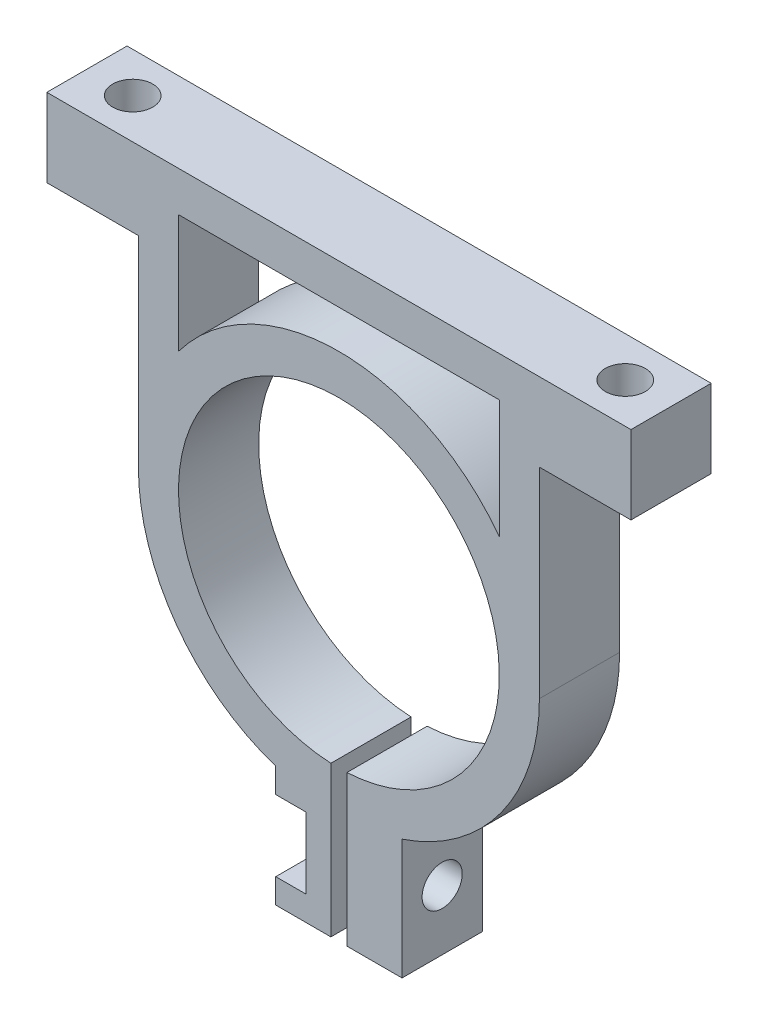
from build123d import *

# Parameters (mm, degrees)
PROFILE_SKETCH_R             = 12.7
PROFILE_EXTRUDE_DEPTH        = 6.35
GAP_SKETCH_W                 = 1.27
GAP_SKETCH_H                 = 17.15262
GAP_CUT_DEPTH                = 7.35
CROSSBOLT_HOLE_SKETCH_R      = 1.5875
CROSSBOLT_HOLE_CUT_DEPTH     = 10
NUT_CAPTURE_POCKET_SKETCH_W  = 4.8
NUT_CAPTURE_POCKET_SKETCH_H  = 5.627
NUT_CAPTURE_POCKET_CUT_DEPTH = 6.35
MOUNTING_HOLE_SKETCH_R       = 1.5875
MOUNTING_HOLE_CUT_DEPTH      = 6.2
LIGHTENING_POCKET_CUT_DEPTH  = 6.35


with BuildPart() as part:
    # Profile Sketch → Profile Extrude (new body)
    with BuildSketch(Plane.XY):
        with BuildLine():
            Line((-15.875, 0), (-15.875, 15.875))
            Line((-15.875, 15.875), (-23.124999989, 15.875))
            Line((-23.124999989, 15.875), (-23.124999989, 22.075))
            Line((-23.124999989, 22.075), (23.124999989, 22.075))
            Line((23.124999989, 22.075), (23.124999989, 15.875))
            Line((23.124999989, 15.875), (15.875, 15.875))
            Line((15.875, 15.875), (15.875, 0))
            ThreePointArc((15.875, 0), (12.872269128, -9.290872537), (5, -15.067037698))
            Line((5, -15.067037698), (5, -24.592037698))
            Line((5, -24.592037698), (-5, -24.592037698))
            Line((-5, -24.592037698), (-5, -15.067037698))
            ThreePointArc((-5, -15.067037698), (-12.872269128, -9.290872537), (-15.875, 0))
        make_face()
        Circle(PROFILE_SKETCH_R, mode=Mode.SUBTRACT)
    extrude(amount=PROFILE_EXTRUDE_DEPTH)

    # Gap Sketch → Gap Cut (cut, through all)
    with BuildSketch(Plane.XY.offset(6.35)):
        with Locations((0, -17.526)):
            Rectangle(GAP_SKETCH_W, GAP_SKETCH_H)
    extrude(amount=-GAP_CUT_DEPTH, mode=Mode.SUBTRACT)

    # Crossbolt Hole Sketch → Crossbolt Hole Cut (cut)
    with BuildSketch(Plane(origin=(5, 0, 0), x_dir=(0, 0, -1), z_dir=(1, 0, 0))):
        with Locations((-3.175, -19.829537698)):
            Circle(CROSSBOLT_HOLE_SKETCH_R)
    extrude(amount=-CROSSBOLT_HOLE_CUT_DEPTH, mode=Mode.SUBTRACT)

    # Nut Capture Pocket Sketch → Nut Capture Pocket Cut (cut)
    with BuildSketch(Plane.XY.offset(6.35)):
        with Locations((-5, -19.829537698)):
            Rectangle(NUT_CAPTURE_POCKET_SKETCH_W, NUT_CAPTURE_POCKET_SKETCH_H)
    extrude(amount=-NUT_CAPTURE_POCKET_CUT_DEPTH, mode=Mode.SUBTRACT)

    # Mounting Hole Sketch → Mounting Hole Cut (cut)
    with BuildSketch(Plane.XZ.offset(-15.875)):
        with Locations((19.499999994, 3.175)):
            Circle(MOUNTING_HOLE_SKETCH_R)
        with Locations((-19.499999995, 3.175)):
            Circle(MOUNTING_HOLE_SKETCH_R)
    extrude(amount=-MOUNTING_HOLE_CUT_DEPTH, mode=Mode.SUBTRACT)

    # Lightening Pocket Sketch → Lightening Pocket Cut (cut)
    with BuildSketch(Plane.XY.offset(6.35)):
        with BuildLine():
            Line((12.7, 18.9), (-12.7, 18.9))
            Line((-12.7, 18.9), (-12.7, 9.525))
            ThreePointArc((-12.7, 9.525), (0, 15.875), (12.7, 9.525))
            Line((12.7, 9.525), (12.7, 18.9))
        make_face()
    extrude(amount=-LIGHTENING_POCKET_CUT_DEPTH, mode=Mode.SUBTRACT)


solid = part.part
